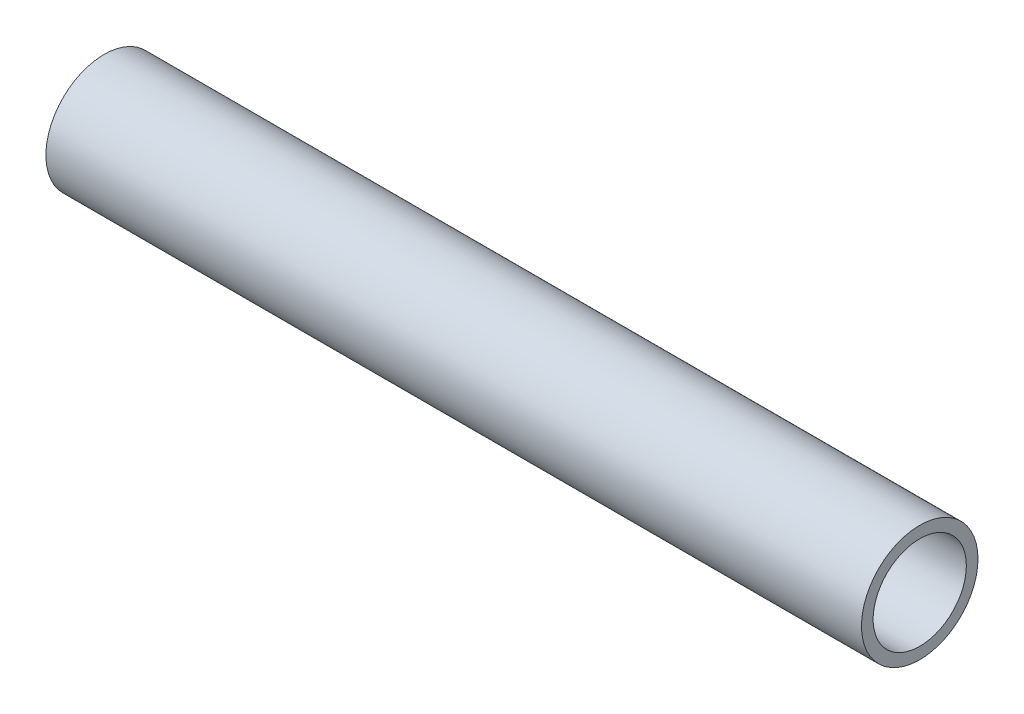
from build123d import *

# Parameters (mm, degrees)
ESQUISSE2_R        = 5
ESQUISSE2_R_2      = 4
BOSS_EXTRU_1_DEPTH = 70


with BuildPart() as part:
    # Esquisse2 → Boss.-Extru.1 (new body)
    with BuildSketch(Plane(origin=(0, 0, 0), x_dir=(0, 0, -1), z_dir=(1, 0, 0))):
        Circle(ESQUISSE2_R)
        Circle(ESQUISSE2_R_2, mode=Mode.SUBTRACT)
    extrude(amount=BOSS_EXTRU_1_DEPTH)


solid = part.part
